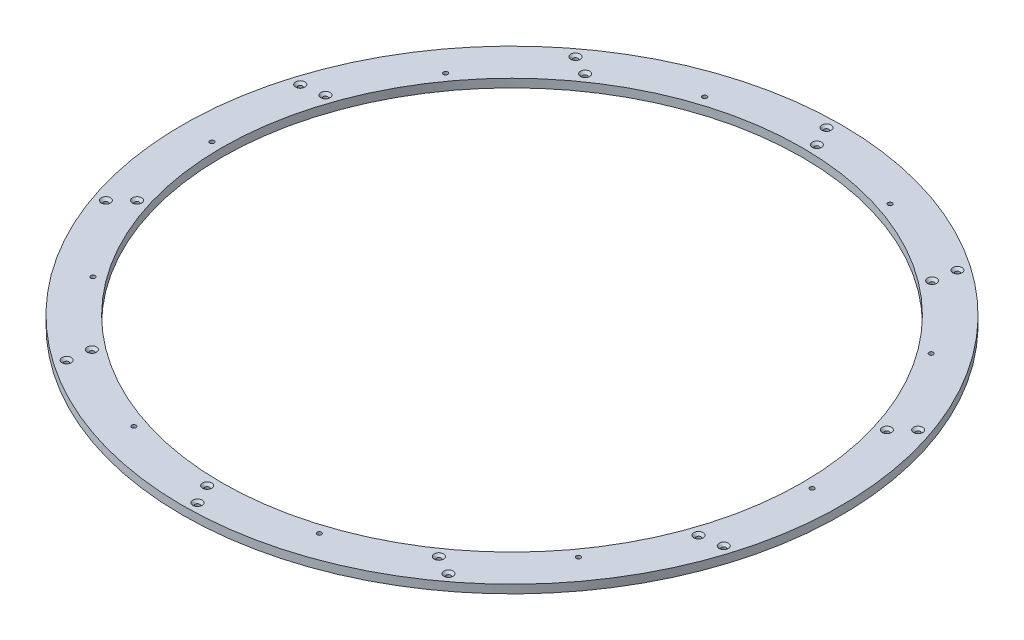
from build123d import *

# Parameters (mm, degrees)
SKETCH1_R                                       = 335
SKETCH1_R_2                                     = 295
BOSS_EXTRUDE1_DEPTH                             = 8.5
CBORE_FOR_M4_SHCS1_D                            = 4.5
CBORE_FOR_M4_SHCS1_CBORE_D                      = 8
CBORE_FOR_M4_SHCS1_CBORE_DEPTH                  = 4
CSK_FOR_M4_FLAT_HEAD_MACHINE_SCREW1_D           = 4.5
CSK_FOR_M4_FLAT_HEAD_MACHINE_SCREW1_CSINK_D     = 9.4
CSK_FOR_M4_FLAT_HEAD_MACHINE_SCREW1_CSINK_ANGLE = 90


with BuildPart() as part:
    # Sketch1 → Boss-Extrude1 (new body)
    with BuildSketch(Plane(origin=(0, 0, 0), x_dir=(1, 0, 0), z_dir=(0, 1, 0))):
        Circle(SKETCH1_R)
        Circle(SKETCH1_R_2, mode=Mode.SUBTRACT)
    extrude(amount=BOSS_EXTRUDE1_DEPTH)

    # CBORE for M4 SHCS1 (through all)
    with Locations(Plane(origin=(-255.59713911, 32.5, 6.312571873), x_dir=(-0.922302375, 0, -0.386469054), z_dir=(0, 1, 0))):
        with Locations((-208.121459337, -408.561577194), (-34.267123624, -335.712018853), (63.564092484, -174.586473543), (48.003989595, 13.270576883), (-75.004001856, 156.104124188), (-258.475010022, 199.356608036), (-432.329345735, 126.507049694), (-530.160561843, -34.618495616), (-514.600458954, -222.475546041), (-391.592467503, -365.309093346)):
            CounterBoreHole(CBORE_FOR_M4_SHCS1_D / 2, CBORE_FOR_M4_SHCS1_CBORE_D / 2, CBORE_FOR_M4_SHCS1_CBORE_DEPTH)

    # CSK for M4 Flat Head Machine Screw1 (through all)
    with Locations(Plane(origin=(68.292311883, 8.5, -24.828551781), x_dir=(1, 0, 0), z_dir=(0, 1, 0))):
        with Locations((-375.726730436, -130.228164158), (-378.9643189, 70.606787878), (-263.535760038, 234.988683892), (-73.530840061, 300.129226742), (118.475019629, 241.146943105), (239.14210667, 80.571060596), (242.379695134, -120.26389144), (126.951136271, -284.645787454), (-63.053783706, -349.786330304), (-255.059643396, -290.804046667), (-359.846041546, -114.390947461), (-356.807689294, 74.084930603), (-243.566269149, 224.779220342), (-63.376154671, 280.131824986), (114.936154846, 218.999930927), (223.261417779, 64.733843899), (220.223065528, -123.742034166), (106.981645382, -274.436323905), (-73.208469096, -329.788928549), (-251.520778613, -268.65703449)):
            CounterSinkHole(CSK_FOR_M4_FLAT_HEAD_MACHINE_SCREW1_D / 2, CSK_FOR_M4_FLAT_HEAD_MACHINE_SCREW1_CSINK_D / 2, counter_sink_angle=CSK_FOR_M4_FLAT_HEAD_MACHINE_SCREW1_CSINK_ANGLE)


solid = part.part
